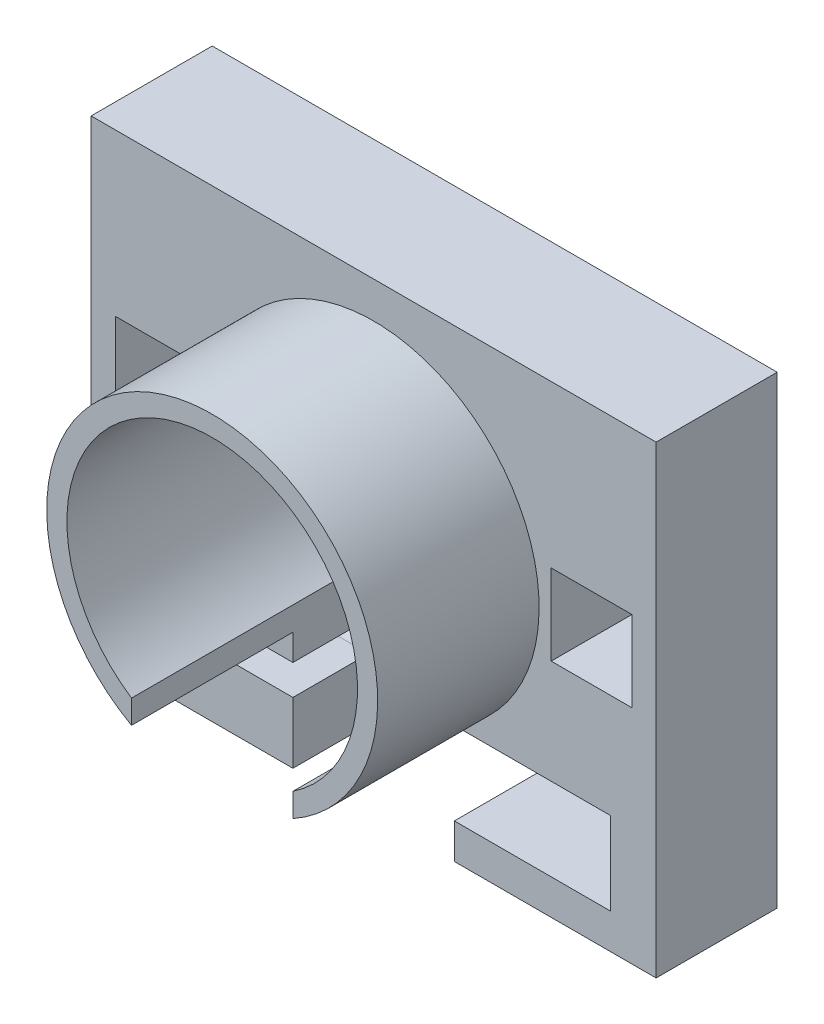
from build123d import *

# Parameters (mm, degrees)
SKETCH_1_W          = 140
SKETCH_1_H          = 115
SKETCH_1_R          = 36
SKETCH_1_W_2        = 20
SKETCH_1_H_2        = 20
EXTRUDE_1_DEPTH     = 30
SKETCH_2_R          = 40
CUT_EXTRUDE_1_DEPTH = 10
SKETCH_10_R         = 41
SKETCH_10_R_2       = 36
EXTRUDE_3_DEPTH     = 40
CUT_EXTRUDE_2_REACH = 117
SKETCH_3_W          = 40
SKETCH_3_H          = 80
SKETCH_4_R          = 3.75
SKETCH_4_W          = 18.75
SKETCH_4_H          = 7.5
CUT_EXTRUDE_3_DEPTH = 15
SKETCH_6_W          = 9.65
SKETCH_6_H          = 20.5
CUT_EXTRUDE_4_DEPTH = 31
SKETCH_7_W          = 29
SKETCH_7_H          = 20.5
CUT_EXTRUDE_5_DEPTH = 21
SKETCH_11_W         = 7
SKETCH_11_H         = 8
CUT_EXTRUDE_6_DEPTH = 10


with BuildPart() as part:
    # 草圖1 → 填料-伸長1 (new body)
    with BuildSketch(Plane.XY):
        with Locations((8.56146046, -0.554151625)):
            Rectangle(SKETCH_1_W, SKETCH_1_H)
        with Locations((8.56146046, 6.945848375)):
            Circle(SKETCH_1_R, mode=Mode.SUBTRACT)
        with Locations((-45.43853954, 6.945848375)):
            Rectangle(SKETCH_1_W_2, SKETCH_1_H_2, mode=Mode.SUBTRACT)
        with Locations((62.56146046, 6.945848375)):
            Rectangle(SKETCH_1_W_2, SKETCH_1_H_2, mode=Mode.SUBTRACT)
    extrude(amount=EXTRUDE_1_DEPTH)

    # 草圖2 → 除料-伸長1 (cut)
    with BuildSketch(Plane(origin=(0, 0, 0), x_dir=(-1, 0, 0), z_dir=(0, 0, -1))):
        with Locations((-8.56146046, 6.945848375)):
            Circle(SKETCH_2_R)
    extrude(amount=-CUT_EXTRUDE_1_DEPTH, mode=Mode.SUBTRACT)

    # 草圖10 → 填料-伸長3 (add)
    with BuildSketch(Plane.XY.offset(30)):
        with Locations((8.56146046, 6.945848375)):
            Circle(SKETCH_10_R)
        with Locations((8.56146046, 6.945848375)):
            Circle(SKETCH_10_R_2, mode=Mode.SUBTRACT)
    extrude(amount=EXTRUDE_3_DEPTH)

    # 草圖3 → 除料-伸長2 (cut, up to next)
    with BuildSketch(Plane.XZ.offset(58.054151625), mode=Mode.PRIVATE) as cut_extrude_2_sk1:
        with Locations((8.56146046, 40)):
            Rectangle(SKETCH_3_W, SKETCH_3_H)
    cut_extrude_2_tool1 = extrude(cut_extrude_2_sk1.sketch, amount=-CUT_EXTRUDE_2_REACH, mode=Mode.PRIVATE) & part.part
    add(cut_extrude_2_tool1.solids().sort_by_distance((8.56146, -58.054152, 40))[0], mode=Mode.SUBTRACT)

    # 草圖4 → 除料-伸長3 (cut)
    with BuildSketch(Plane(origin=(-11.43853954, 0, 0), x_dir=(0, 0, -1), z_dir=(1, 0, 0))):
        with Locations((-11.25, -39.095211961)):
            Circle(SKETCH_4_R)
        with Locations((-20.625, -39.095211961)):
            Rectangle(SKETCH_4_W, SKETCH_4_H)
    extrude(amount=-CUT_EXTRUDE_3_DEPTH, mode=Mode.SUBTRACT)

    # 草圖6 → 除料-伸長4 (cut, through all)
    with BuildSketch(Plane.XY.offset(30)):
        with Locations((33.38646046, -39.095211961)):
            Rectangle(SKETCH_6_W, SKETCH_6_H)
    extrude(amount=-CUT_EXTRUDE_4_DEPTH, mode=Mode.SUBTRACT)

    # 草圖7 → 除料-伸長5 (cut)
    with BuildSketch(Plane.XY.offset(30)):
        with Locations((52.71146046, -39.095211961)):
            Rectangle(SKETCH_7_W, SKETCH_7_H)
    extrude(amount=-CUT_EXTRUDE_5_DEPTH, mode=Mode.SUBTRACT)

    # 草圖11 → 除料-伸長6 (cut)
    with BuildSketch(Plane.XY.offset(9)):
        with Locations((60.71146046, -39.095211961)):
            Rectangle(SKETCH_11_W, SKETCH_11_H)
    extrude(amount=-CUT_EXTRUDE_6_DEPTH, mode=Mode.SUBTRACT)


solid = part.part
